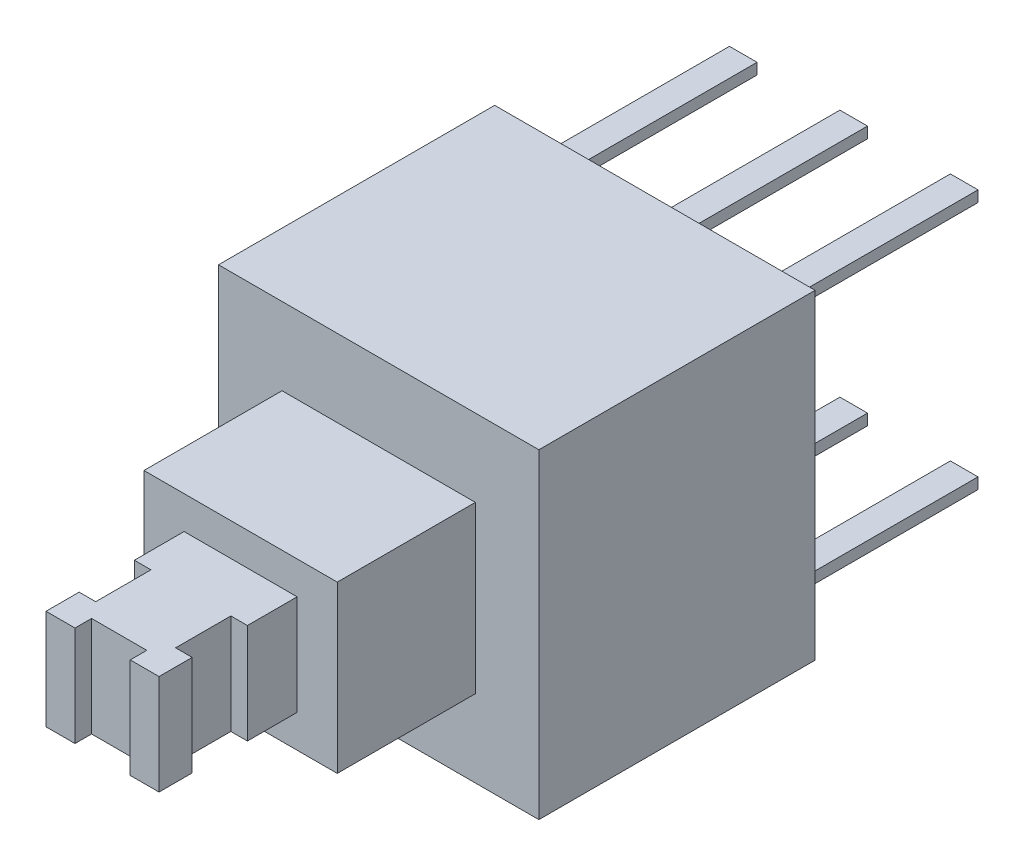
from build123d import *

# Parameters (mm, degrees)
SKETCH1_W           = 5.8
SKETCH1_H           = 5.8
BOSS_EXTRUDE2_DEPTH = 5
SKETCH3_W           = 3.5
SKETCH3_H           = 3
BOSS_EXTRUDE3_DEPTH = 2.5
SKETCH4_W           = 2.046388996
SKETCH4_H           = 1.811822668
BOSS_EXTRUDE4_DEPTH = 2.5
SKETCH5_W           = 0.5
SKETCH5_H           = 0.2
BOSS_EXTRUDE5_DEPTH = 3.6
SKETCH6_W           = 1
SKETCH6_H           = 0.3
SKETCH6_W_2         = 0.3
SKETCH6_H_2         = 1
CUT_EXTRUDE1_DEPTH  = 2


with BuildPart() as part:
    # Sketch1 → Boss-Extrude2 (new body)
    with BuildSketch(Plane.XY):
        with Locations((2.9, 2.9)):
            Rectangle(SKETCH1_W, SKETCH1_H)
    extrude(amount=BOSS_EXTRUDE2_DEPTH)

    # Sketch3 → Boss-Extrude3 (add)
    with BuildSketch(Plane.XY.offset(5)):
        with Locations((2.9, 2.9)):
            Rectangle(SKETCH3_W, SKETCH3_H)
    extrude(amount=BOSS_EXTRUDE3_DEPTH)

    # Sketch4 → Boss-Extrude4 (add)
    with BuildSketch(Plane.XY.offset(7.5)):
        with Locations((2.9, 2.9)):
            Rectangle(SKETCH4_W, SKETCH4_H)
    extrude(amount=BOSS_EXTRUDE4_DEPTH)

    # Sketch5 → Boss-Extrude5 (add)
    with BuildSketch(Plane(origin=(0, 0, 0), x_dir=(-1, 0, 0), z_dir=(0, 0, -1))):
        with Locations((-4.9, 5.15)):
            Rectangle(SKETCH5_W, SKETCH5_H)
        with Locations((-2.9, 5.15)):
            Rectangle(SKETCH5_W, SKETCH5_H)
        with Locations((-0.9, 5.15)):
            Rectangle(SKETCH5_W, SKETCH5_H)
        with Locations((-0.9, 0.65)):
            Rectangle(SKETCH5_W, SKETCH5_H)
        with Locations((-2.9, 0.65)):
            Rectangle(SKETCH5_W, SKETCH5_H)
        with Locations((-4.9, 0.65)):
            Rectangle(SKETCH5_W, SKETCH5_H)
    extrude(amount=BOSS_EXTRUDE5_DEPTH)

    # Sketch6 → Cut-Extrude1 (cut)
    with BuildSketch(Plane.XZ.offset(-1.994088666)):
        with Locations((2.901805502, 9.85)):
            Rectangle(SKETCH6_W, SKETCH6_H)
        with Locations((2.026805502, 8.9)):
            Rectangle(SKETCH6_W_2, SKETCH6_H_2)
        with Locations((3.773194498, 8.9)):
            Rectangle(SKETCH6_W_2, SKETCH6_H_2)
    extrude(amount=-CUT_EXTRUDE1_DEPTH, mode=Mode.SUBTRACT)


solid = part.part
